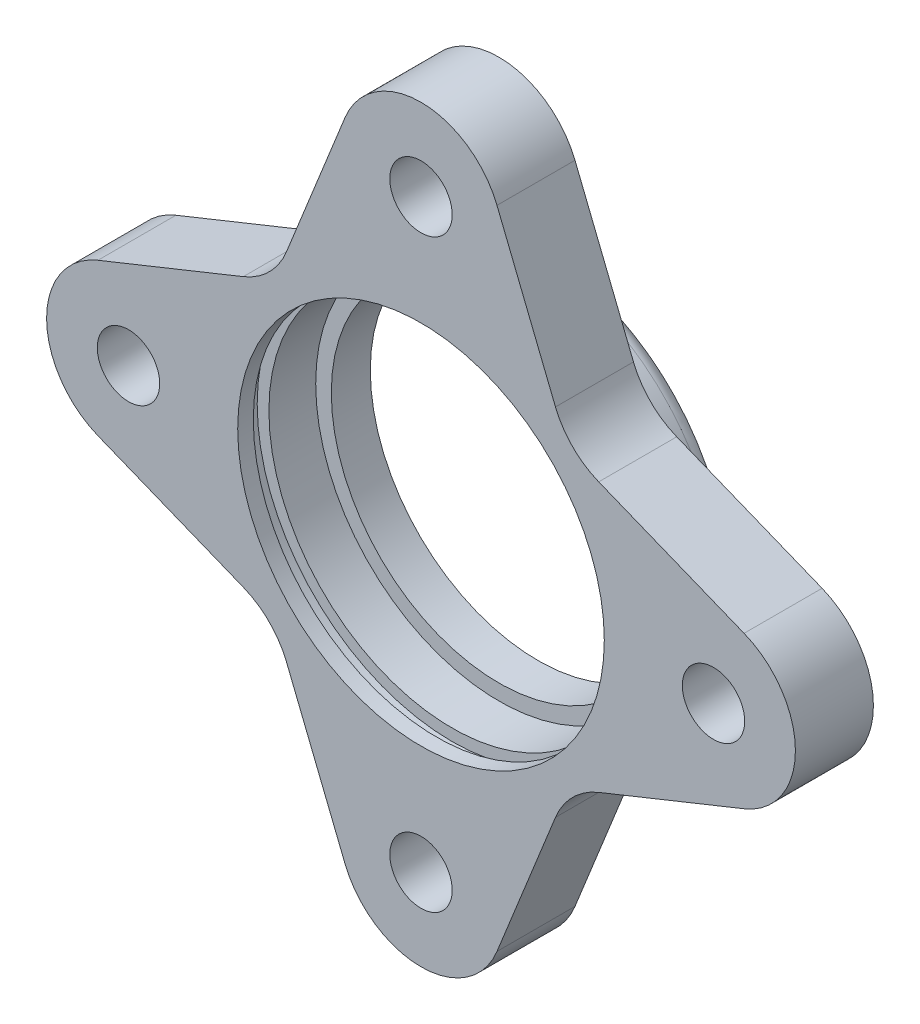
from build123d import *

# Parameters (mm, degrees)
SKETCH1_R           = 48
SKETCH1_R_2         = 23.5
SKETCH1_R_3         = 4
BOSS_EXTRUDE1_DEPTH = 10
CUT_EXTRUDE3_START  = -2
SKETCH2_R           = 25
SKETCH2_R_2         = 23.5
CUT_EXTRUDE3_DEPTH  = 2
CUT_EXTRUDE4_DEPTH  = 11
CIRPATTERN4_COUNT   = 4
SKETCH4_R           = 25.5
SKETCH4_R_2         = 21.5
BOSS_EXTRUDE2_DEPTH = 5
FILLET1_R           = 2
FILLET2_R           = 1


with BuildPart() as part:
    # Sketch1 → Boss-Extrude1 (new body)
    with BuildSketch(Plane.XY):
        Circle(SKETCH1_R)
        Circle(SKETCH1_R_2, mode=Mode.SUBTRACT)
        with Locations((37.5, 0)):
            Circle(SKETCH1_R_3, mode=Mode.SUBTRACT)
        with Locations((0, 37.5)):
            Circle(SKETCH1_R_3, mode=Mode.SUBTRACT)
        with Locations((-37.5, 0)):
            Circle(SKETCH1_R_3, mode=Mode.SUBTRACT)
        with Locations((0, -37.5)):
            Circle(SKETCH1_R_3, mode=Mode.SUBTRACT)
    extrude(amount=BOSS_EXTRUDE1_DEPTH)

    # Sketch2 → Cut-Extrude3 (cut)
    with BuildSketch(Plane.XY.offset(10).offset(CUT_EXTRUDE3_START)):
        Circle(SKETCH2_R)
        Circle(SKETCH2_R_2, mode=Mode.SUBTRACT)
    extrude(amount=-CUT_EXTRUDE3_DEPTH, mode=Mode.SUBTRACT)

    # Sketch3 → Cut-Extrude4 (cut, through all)
    with BuildSketch(Plane(origin=(0, 0, 0), x_dir=(-1, 0, 0), z_dir=(0, 0, -1))):
        with BuildLine():
            Line((-9.741058681, 41.419410131), (-17.239305551, 22.783732741))
            ThreePointArc((-17.239305551, 22.783732741), (-19.445436483, 19.445436483), (-22.783732741, 17.239305551))
            Line((-22.783732741, 17.239305551), (-41.419410131, 9.741058681))
            ThreePointArc((-41.419410131, 9.741058681), (-46.200684064, 5.877762909), (-48, 0))
            ThreePointArc((-48, 0), (-33.941125497, 33.941125497), (0, 48))
            ThreePointArc((0, 48), (-5.877762909, 46.200684064), (-9.741058681, 41.419410131))
        make_face()
    cut_extrude4 = extrude(amount=-CUT_EXTRUDE4_DEPTH, mode=Mode.SUBTRACT)

    # CirPattern4: Cut-Extrude4 ×4 about axis
    cirpattern4_axis = Axis((0, 0, 0), (0, 0, 1))
    for i in range(1, CIRPATTERN4_COUNT):
        add(cut_extrude4.rotate(cirpattern4_axis, i * 360 / CIRPATTERN4_COUNT), mode=Mode.SUBTRACT)

    # Sketch4 → Boss-Extrude2 (add)
    with BuildSketch(Plane(origin=(0, 0, 0), x_dir=(-1, 0, 0), z_dir=(0, 0, -1))):
        Circle(SKETCH4_R)
        Circle(SKETCH4_R_2, mode=Mode.SUBTRACT)
    extrude(amount=BOSS_EXTRUDE2_DEPTH)

    # Fillet1
    fillet1_edges = [part.edges().sort_by_distance(p)[0] for p in [
        (25.5, 0, -5),
    ]]
    fillet(fillet1_edges, radius=FILLET1_R)

    # Fillet2
    fillet2_edges = [part.edges().sort_by_distance(p)[0] for p in [
        (25.5, 0, 0),
    ]]
    fillet(fillet2_edges, radius=FILLET2_R)


solid = part.part
